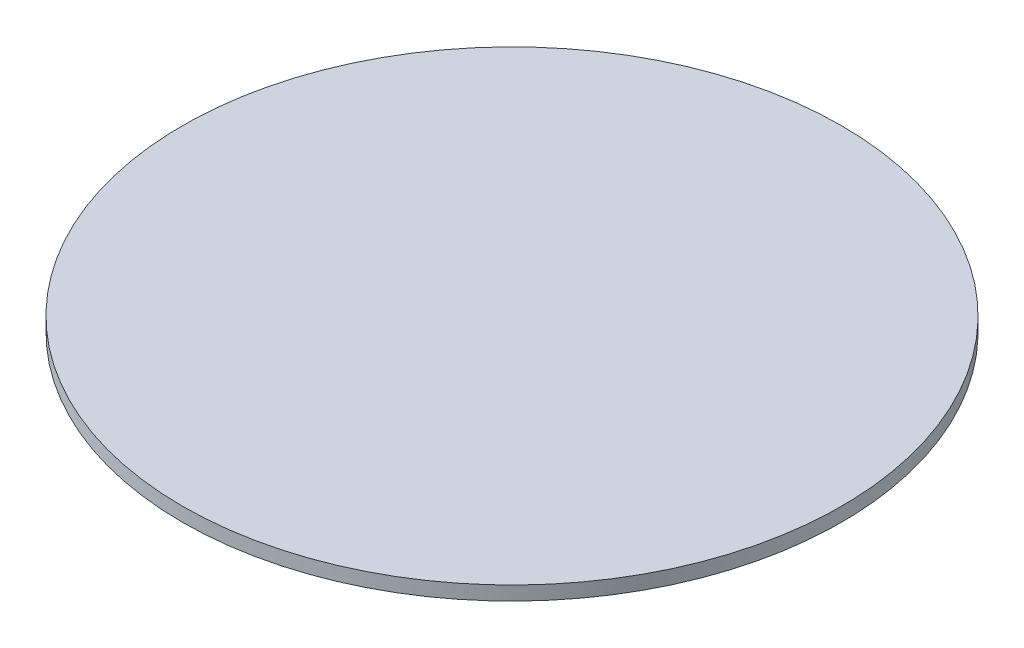
from build123d import *

# Parameters (mm, degrees)
SKETCH1_R           = 150
BOSS_EXTRUDE1_DEPTH = 6.35


with BuildPart() as part:
    # Sketch1 → Boss-Extrude1 (new body)
    with BuildSketch(Plane(origin=(0, 0, 0), x_dir=(1, 0, 0), z_dir=(0, 1, 0))):
        Circle(SKETCH1_R)
    extrude(amount=BOSS_EXTRUDE1_DEPTH)


solid = part.part
